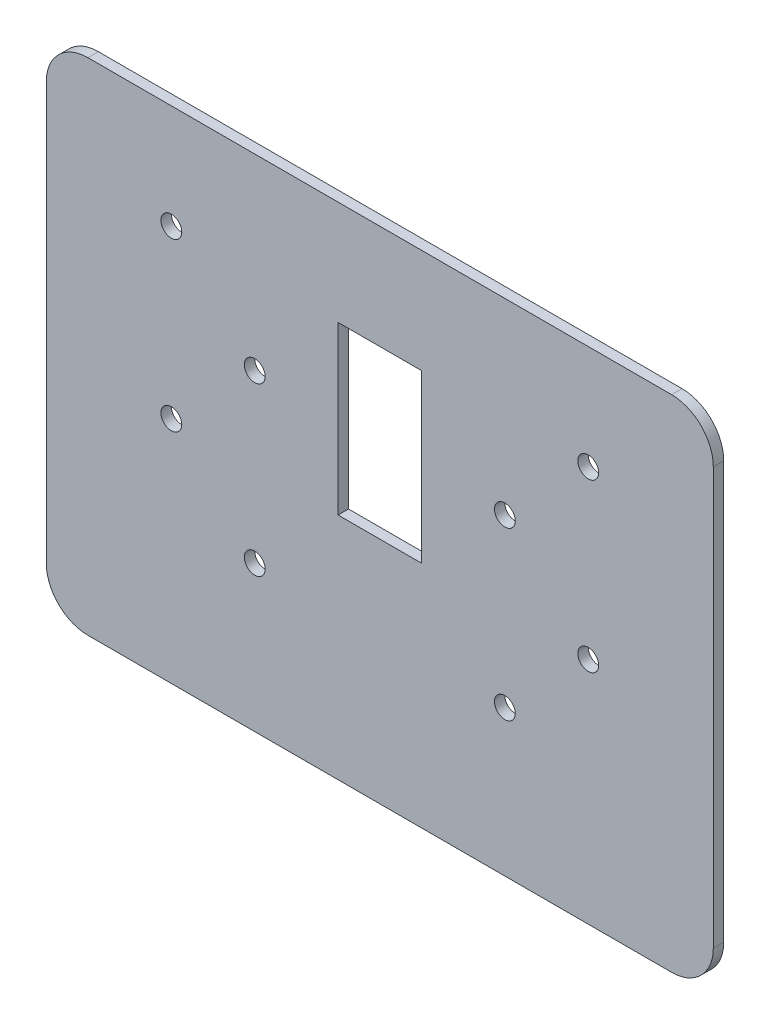
from build123d import *

# Parameters (mm, degrees)
SKETCH1_R           = 3.175
SKETCH1_W           = 25.4
SKETCH1_H           = 50.8
BOSS_EXTRUDE1_DEPTH = 3.175


with BuildPart() as part:
    # Sketch1 → Boss-Extrude1 (new body)
    with BuildSketch(Plane.XY):
        with BuildLine():
            Line((-392.019369126, 463.520831078), (-214.219369126, 463.520831078))
            ThreePointArc((-214.219369126, 463.520831078), (-205.239113005, 459.801087199), (-201.519369126, 450.820831078))
            Line((-201.519369126, 450.820831078), (-201.519369126, 323.820831078))
            ThreePointArc((-201.519369126, 323.820831078), (-205.239113005, 314.840574957), (-214.219369126, 311.120831078))
            Line((-214.219369126, 311.120831078), (-392.019369126, 311.120831078))
            ThreePointArc((-392.019369126, 311.120831078), (-400.999625247, 314.840574957), (-404.719369126, 323.820831078))
            Line((-404.719369126, 323.820831078), (-404.719369126, 450.820831078))
            ThreePointArc((-404.719369126, 450.820831078), (-400.999625247, 459.801087199), (-392.019369126, 463.520831078))
        make_face()
        with Locations((-239.619369126, 431.770831078)):
            Circle(SKETCH1_R, mode=Mode.SUBTRACT)
        with Locations((-239.619369126, 380.970831078)):
            Circle(SKETCH1_R, mode=Mode.SUBTRACT)
        with Locations((-265.019369126, 406.370831078)):
            Circle(SKETCH1_R, mode=Mode.SUBTRACT)
        with Locations((-366.619369126, 380.970831078)):
            Circle(SKETCH1_R, mode=Mode.SUBTRACT)
        with Locations((-341.219369126, 406.370831078)):
            Circle(SKETCH1_R, mode=Mode.SUBTRACT)
        with Locations((-366.619369126, 431.770831078)):
            Circle(SKETCH1_R, mode=Mode.SUBTRACT)
        with Locations((-265.019369126, 355.570831078)):
            Circle(SKETCH1_R, mode=Mode.SUBTRACT)
        with Locations((-341.219369126, 355.570831078)):
            Circle(SKETCH1_R, mode=Mode.SUBTRACT)
        with Locations((-303.119369126, 406.370831078)):
            Rectangle(SKETCH1_W, SKETCH1_H, mode=Mode.SUBTRACT)
    extrude(amount=BOSS_EXTRUDE1_DEPTH)


solid = part.part
